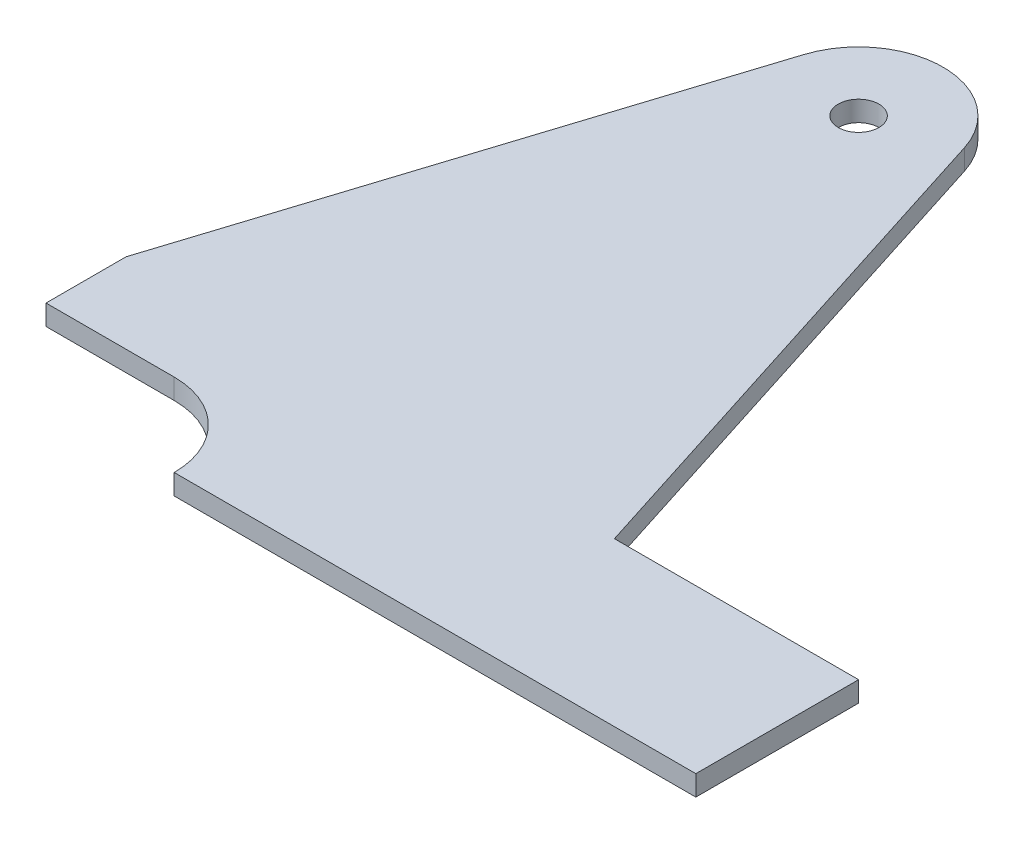
from build123d import *

# Parameters (mm, degrees)
SKETCH1_R           = 6.35
BOSS_EXTRUDE1_DEPTH = 6.35


with BuildPart() as part:
    # Sketch1 → Boss-Extrude1 (new body)
    with BuildSketch(Plane(origin=(0, 0, 0), x_dir=(1, 0, 0), z_dir=(0, 1, 0))):
        with BuildLine():
            Line((76.2, -152.4), (25.106996492, 7.99757633))
            ThreePointArc((25.106996492, 7.99757633), (0, 26.35), (-25.106996492, 7.99757633))
            Line((-25.106996492, 7.99757633), (-76.2, -152.4))
            Line((-76.2, -152.4), (-76.2, -177.4))
            Line((-76.2, -177.4), (-36.2, -177.4))
            ThreePointArc((-36.2, -177.4), (-17.956645045, -184.956645045), (-10.4, -203.2))
            Line((-10.4, -203.2), (152.4, -203.2))
            Line((152.4, -203.2), (152.4, -152.4))
            Line((152.4, -152.4), (76.2, -152.4))
        make_face()
        Circle(SKETCH1_R, mode=Mode.SUBTRACT)
    extrude(amount=BOSS_EXTRUDE1_DEPTH)


solid = part.part
